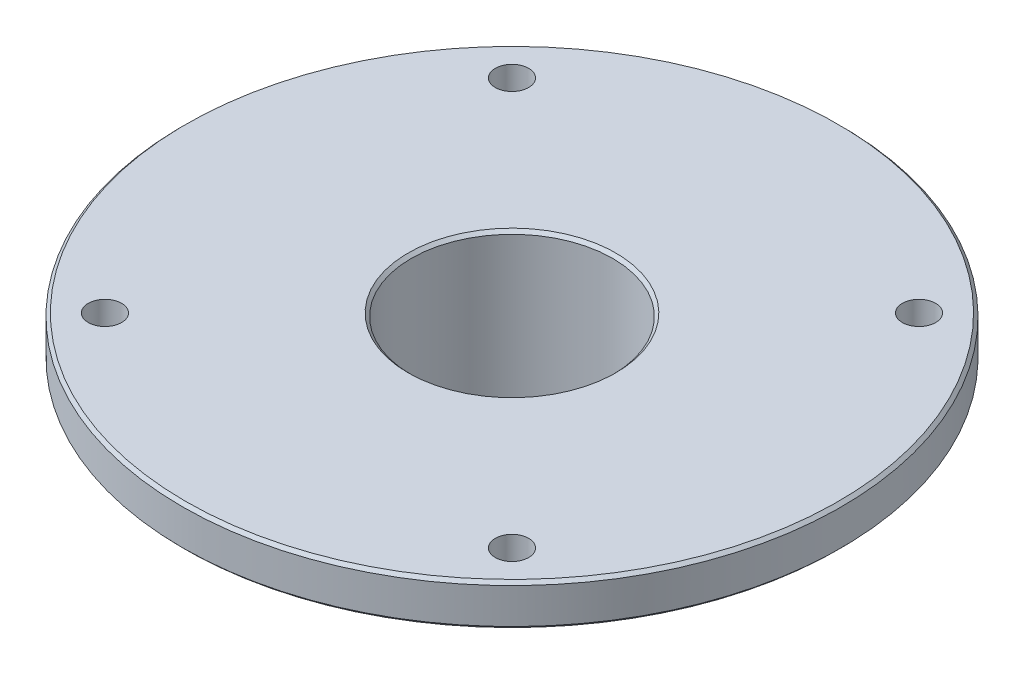
from build123d import *

# Parameters (mm, degrees)
CUT_EXTRUDE1_REACH = 42
SKETCH2_R          = 4
CHAMFER1_SIZE      = 0.75


with BuildPart() as part:
    # Sketch1 → Revolve1 (revolve)
    with BuildSketch(Plane.XY):
        Polygon((-24.15, 5.519256014), (-24.15, -34.480743986), (-30, -34.480743986), (-30, -6.480743986), (-36, -6.480743986), (-36, -4.480743986), (-79, -4.480743986), (-79, 5.519256014), align=None)
    revolve(axis=Axis((0, 0, 0), (0, -1, 0)))

    # Sketch2 → Cut-Extrude1 (cut, up to next)
    with BuildSketch(Plane(origin=(0, 5.519256014, 0), x_dir=(1, 0, 0), z_dir=(0, 1, 0)), mode=Mode.PRIVATE) as cut_extrude1_sk1:
        with Locations((48.790367902, 48.790367902)):
            Circle(SKETCH2_R)
    cut_extrude1_tool1 = extrude(cut_extrude1_sk1.sketch, amount=-CUT_EXTRUDE1_REACH, mode=Mode.PRIVATE) & part.part
    add(cut_extrude1_tool1.solids().sort_by_distance((48.790368, 5.519256, -48.790368))[0], mode=Mode.SUBTRACT)
    # Sketch2 → Cut-Extrude1 (cut, up to next)
    with BuildSketch(Plane(origin=(0, 5.519256014, 0), x_dir=(1, 0, 0), z_dir=(0, 1, 0)), mode=Mode.PRIVATE) as cut_extrude1_sk2:
        with Locations((48.790367902, -48.790367902)):
            Circle(SKETCH2_R)
    cut_extrude1_tool2 = extrude(cut_extrude1_sk2.sketch, amount=-CUT_EXTRUDE1_REACH, mode=Mode.PRIVATE) & part.part
    add(cut_extrude1_tool2.solids().sort_by_distance((48.790368, 5.519256, 48.790368))[0], mode=Mode.SUBTRACT)
    # Sketch2 → Cut-Extrude1 (cut, up to next)
    with BuildSketch(Plane(origin=(0, 5.519256014, 0), x_dir=(1, 0, 0), z_dir=(0, 1, 0)), mode=Mode.PRIVATE) as cut_extrude1_sk3:
        with Locations((-48.790367902, -48.790367902)):
            Circle(SKETCH2_R)
    cut_extrude1_tool3 = extrude(cut_extrude1_sk3.sketch, amount=-CUT_EXTRUDE1_REACH, mode=Mode.PRIVATE) & part.part
    add(cut_extrude1_tool3.solids().sort_by_distance((-48.790368, 5.519256, 48.790368))[0], mode=Mode.SUBTRACT)
    # Sketch2 → Cut-Extrude1 (cut, up to next)
    with BuildSketch(Plane(origin=(0, 5.519256014, 0), x_dir=(1, 0, 0), z_dir=(0, 1, 0)), mode=Mode.PRIVATE) as cut_extrude1_sk4:
        with Locations((-48.790367902, 48.790367902)):
            Circle(SKETCH2_R)
    cut_extrude1_tool4 = extrude(cut_extrude1_sk4.sketch, amount=-CUT_EXTRUDE1_REACH, mode=Mode.PRIVATE) & part.part
    add(cut_extrude1_tool4.solids().sort_by_distance((-48.790368, 5.519256, -48.790368))[0], mode=Mode.SUBTRACT)

    # Chamfer1
    chamfer1_edges = [part.edges().sort_by_distance(p)[0] for p in [
        (79, 5.519256014, 0),
        (79, -4.480743986, 0),
        (30, -34.480743986, 0),
        (24.15, -34.480743986, 0),
        (24.15, 5.519256014, 0),
    ]]
    chamfer(chamfer1_edges, length=CHAMFER1_SIZE)


solid = part.part
